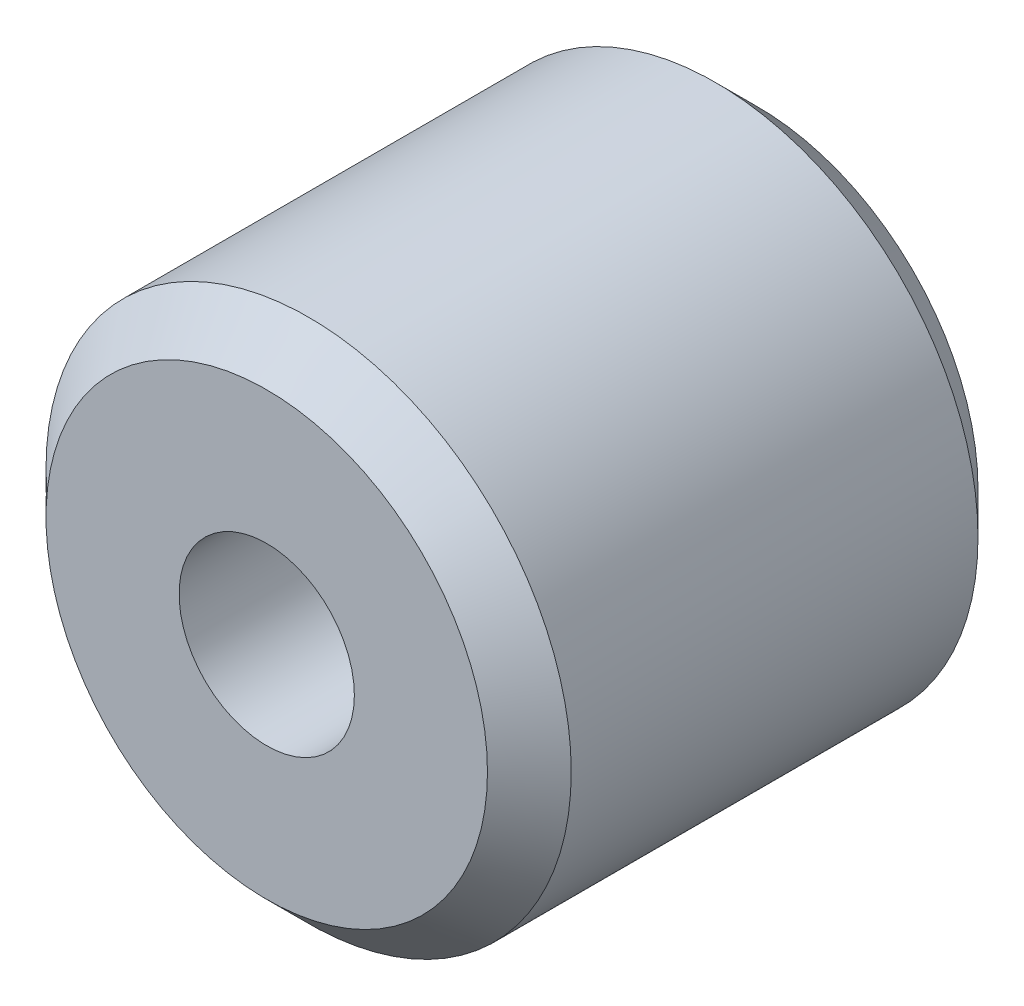
from build123d import *

# Parameters (mm, degrees)
ESQUISSE1_R        = 4.765
ESQUISSE1_R_2      = 1.59
BOSS_EXTRU_1_DEPTH = 4.45
CHANFREIN1_SIZE    = 0.76


with BuildPart() as part:
    # Esquisse1 → Boss.-Extru.1 (new body, symmetric)
    with BuildSketch(Plane.XY):
        Circle(ESQUISSE1_R)
        Circle(ESQUISSE1_R_2, mode=Mode.SUBTRACT)
    extrude(amount=BOSS_EXTRU_1_DEPTH, both=True)

    # Chanfrein1
    chanfrein1_edges = [part.edges().sort_by_distance(p)[0] for p in [
        (-4.765, 0, -4.45),
        (-4.765, 0, 4.45),
    ]]
    chamfer(chanfrein1_edges, length=CHANFREIN1_SIZE)


solid = part.part
